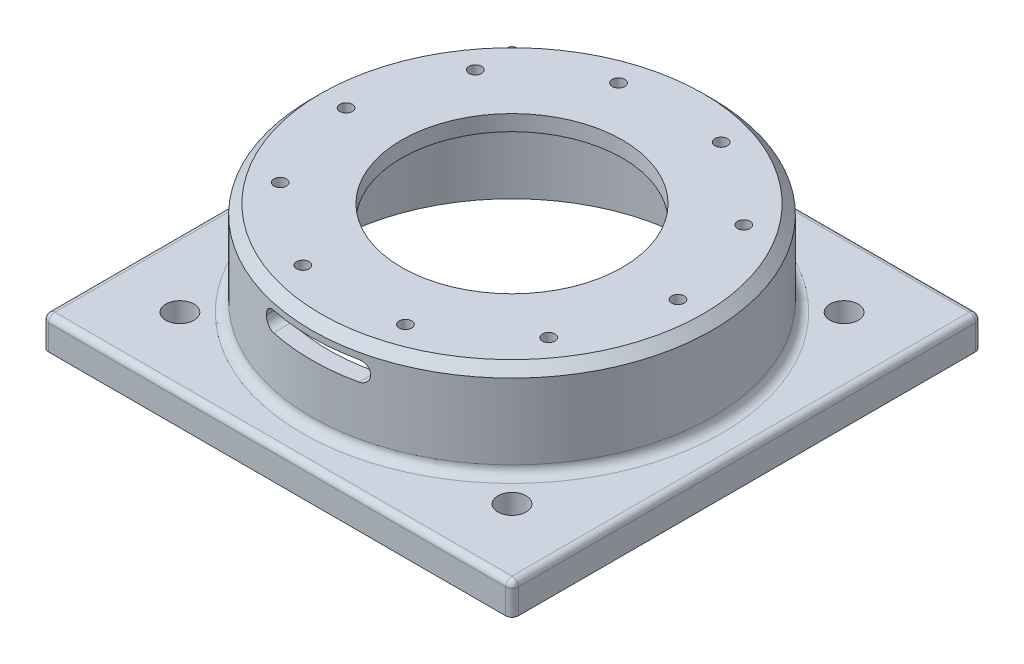
from build123d import *

# Parameters (mm, degrees)
SKETCH_1_W          = 150
SKETCH_1_H          = 150
SKETCH_1_R          = 4.5
EXTRUDE_1_DEPTH     = 10
FILLET_1_R          = 2
FILLET_2_R          = 2
SKETCH_4_R          = 64
EXTRUDE_4_DEPTH     = 30
FILLET_5_R          = 3
SKETCH_11_R         = 35.25
CUT_EXTRUDE_2_DEPTH = 41
SKETCH_10_R         = 58.5
CUT_EXTRUDE_3_DEPTH = 35
SKETCH_12_R         = 2
CUT_EXTRUDE_4_DEPTH = 41
CHAMFER_2_SIZE      = 3
SKETCH_14_W         = 33.25
SKETCH_14_H         = 6.25
CUT_EXTRUDE_5_DEPTH = 9
FILLET_7_R          = 3


with BuildPart() as part:
    # Эскиз1 → Бобышка-Вытянуть1 (new body)
    with BuildSketch(Plane(origin=(0, 0, 0), x_dir=(1, 0, 0), z_dir=(0, 1, 0))):
        Rectangle(SKETCH_1_W, SKETCH_1_H)
        with Locations((53.033008589, 53.033008589)):
            Circle(SKETCH_1_R, mode=Mode.SUBTRACT)
        with Locations((53.033008589, -53.033008589)):
            Circle(SKETCH_1_R, mode=Mode.SUBTRACT)
        with Locations((-53.033008589, -53.033008589)):
            Circle(SKETCH_1_R, mode=Mode.SUBTRACT)
        with Locations((-53.033008589, 53.033008589)):
            Circle(SKETCH_1_R, mode=Mode.SUBTRACT)
    extrude(amount=EXTRUDE_1_DEPTH)

    # Скругление1
    fillet_1_edges = [part.edges().sort_by_distance(p)[0] for p in [
        (-75, 5, -75),
        (75, 5, -75),
        (75, 5, 75),
        (-75, 5, 75),
    ]]
    fillet(fillet_1_edges, radius=FILLET_1_R)

    # Скругление2
    fillet_2_edges = [part.edges().sort_by_distance(p)[0] for p in [
        (-75, 10, 0),
        (0, 10, -75),
        (0, 10, 75),
        (75, 10, 0),
        (74.414213562, 10, 74.414213562),
        (-74.414213562, 10, 74.414213562),
        (74.414213562, 10, -74.414213562),
        (-74.414213562, 10, -74.414213562),
    ]]
    fillet(fillet_2_edges, radius=FILLET_2_R)

    # Эскиз4 → Бобышка-Вытянуть4 (add)
    with BuildSketch(Plane(origin=(0, 10, 0), x_dir=(1, 0, 0), z_dir=(0, 1, 0))):
        Circle(SKETCH_4_R)
    extrude(amount=EXTRUDE_4_DEPTH)

    # Скругление5
    fillet_5_edges = [part.edges().sort_by_distance(p)[0] for p in [
        (-64, 10, 0),
    ]]
    fillet(fillet_5_edges, radius=FILLET_5_R)

    # Эскиз11 → Вырез-Вытянуть2 (cut, through all)
    with BuildSketch(Plane(origin=(0, 40, 0), x_dir=(1, 0, 0), z_dir=(0, 1, 0))):
        Circle(SKETCH_11_R)
    extrude(amount=-CUT_EXTRUDE_2_DEPTH, mode=Mode.SUBTRACT)

    # Эскиз10 → Вырез-Вытянуть3 (cut)
    with BuildSketch(Plane.XZ):
        Circle(SKETCH_10_R)
    extrude(amount=-CUT_EXTRUDE_3_DEPTH, mode=Mode.SUBTRACT)

    # Эскиз12 → Вырез-Вытянуть4 (cut, through all)
    with BuildSketch(Plane(origin=(0, 40, 0), x_dir=(1, 0, 0), z_dir=(0, 1, 0))):
        with Locations((-53, 0)):
            Circle(SKETCH_12_R)
        with Locations((-42.877900702, 31.152618372)):
            Circle(SKETCH_12_R)
        with Locations((-16.377900702, 50.405995364)):
            Circle(SKETCH_12_R)
        with Locations((16.377900702, 50.405995364)):
            Circle(SKETCH_12_R)
        with Locations((42.877900702, 31.152618372)):
            Circle(SKETCH_12_R)
        with Locations((53, 0)):
            Circle(SKETCH_12_R)
        with Locations((42.877900702, -31.152618372)):
            Circle(SKETCH_12_R)
        with Locations((16.377900702, -50.405995364)):
            Circle(SKETCH_12_R)
        with Locations((-16.377900702, -50.405995364)):
            Circle(SKETCH_12_R)
        with Locations((-42.877900702, -31.152618372)):
            Circle(SKETCH_12_R)
    extrude(amount=-CUT_EXTRUDE_4_DEPTH, mode=Mode.SUBTRACT)

    # Фаска2
    chamfer_2_edges = [part.edges().sort_by_distance(p)[0] for p in [
        (-64, 40, 0),
    ]]
    chamfer(chamfer_2_edges, length=CHAMFER_2_SIZE)

    # Эскиз14 → Вырез-Вытянуть5 (cut)
    with BuildSketch(Plane.XY.offset(64)):
        with Locations((0, 31.875)):
            Rectangle(SKETCH_14_W, SKETCH_14_H)
    extrude(amount=-CUT_EXTRUDE_5_DEPTH, mode=Mode.SUBTRACT)

    # Скругление7
    fillet_7_edges = [part.edges().sort_by_distance(p)[0] for p in [
        (-16.625, 28.75, 58.945474725),
        (-16.625, 35, 58.945474725),
        (16.625, 35, 58.945474725),
        (16.625, 28.75, 58.945474725),
    ]]
    fillet(fillet_7_edges, radius=FILLET_7_R)


solid = part.part
